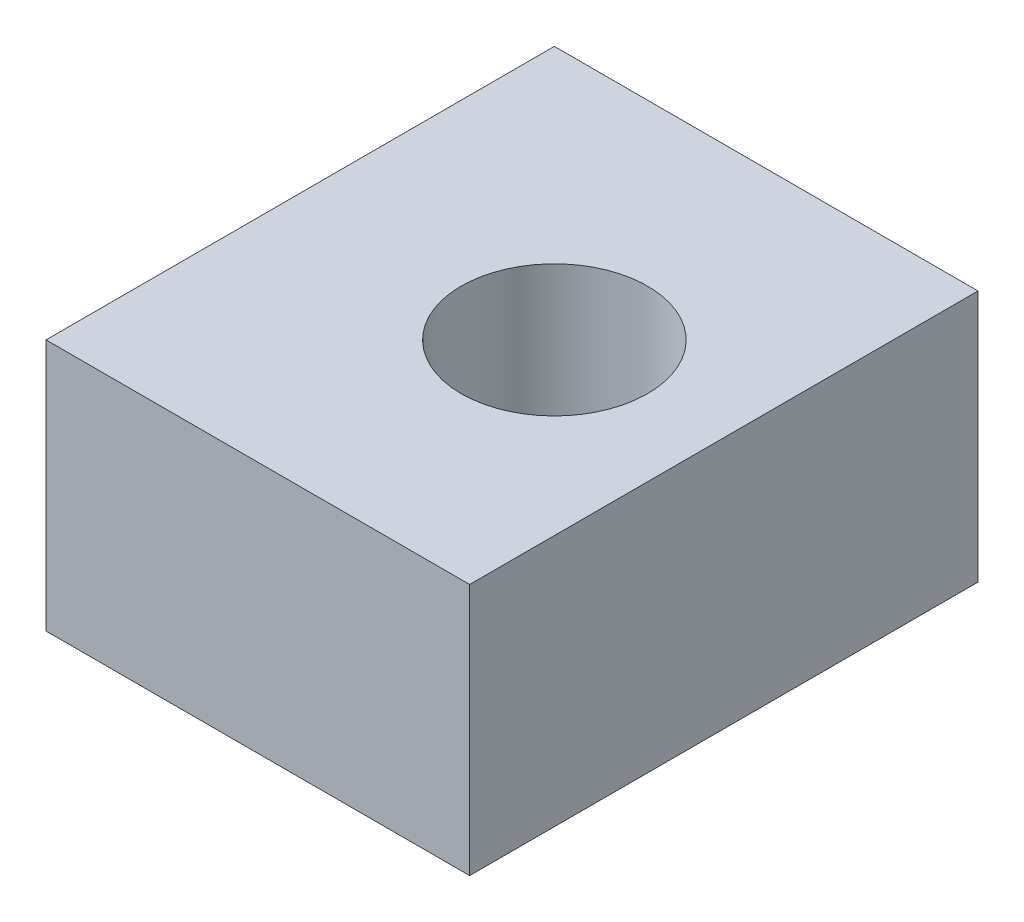
from build123d import *

# Parameters (mm, degrees)
SKETCH1_W           = 15.875
SKETCH1_H           = 19.05
SKETCH1_R           = 3.4925
BOSS_EXTRUDE1_DEPTH = 9.4488


with BuildPart() as part:
    # Sketch1 → Boss-Extrude1 (new body)
    with BuildSketch(Plane(origin=(0, 0, 0), x_dir=(1, 0, 0), z_dir=(0, 1, 0))):
        with Locations((-1.5875, 0)):
            Rectangle(SKETCH1_W, SKETCH1_H)
        Circle(SKETCH1_R, mode=Mode.SUBTRACT)
    extrude(amount=BOSS_EXTRUDE1_DEPTH)


solid = part.part
